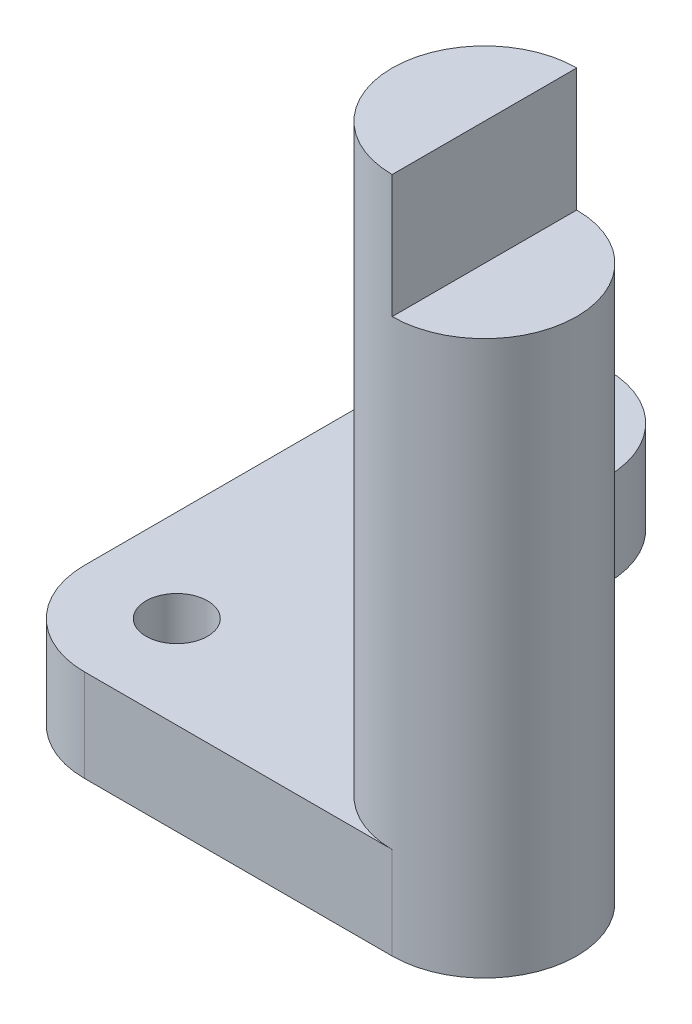
from build123d import *

# Parameters (mm, degrees)
SKETCH1_R           = 0.5
BOSS_EXTRUDE1_DEPTH = 1.5
SKETCH2_R           = 1.5
BOSS_EXTRUDE2_DEPTH = 12
SKETCH3_R           = 0.5
BOSS_EXTRUDE3_DEPTH = 1.5
SKETCH6_W           = 11.188914533
SKETCH6_H           = 9.773285444
CUT_EXTRUDE4_DEPTH  = 6
BOSS_EXTRUDE4_DEPTH = 2


with BuildPart() as part:
    # Sketch1 → Boss-Extrude1 (new body)
    with BuildSketch(Plane(origin=(0, 0, 0), x_dir=(1, 0, 0), z_dir=(0, 1, 0))):
        with BuildLine():
            Line((5, -1), (1.5, -1))
            Line((1.5, -1), (1.5, 2.5))
            Line((1.5, 2.5), (1.5, 3))
            ThreePointArc((1.5, 3), (0, 4.5), (-1.5, 3))
            Line((-1.5, 3), (-1.5, 2.5))
            Line((-1.5, 2.5), (-1.5, -2.5))
            ThreePointArc((-1.5, -2.5), (-1.060660172, -3.560660172), (0, -4))
            Line((0, -4), (5, -4))
            ThreePointArc((5, -4), (6.5, -2.5), (5, -1))
        make_face()
        with Locations((0, -2.5)):
            Circle(SKETCH1_R, mode=Mode.SUBTRACT)
        with BuildLine():
            Line((-0.5, 3), (-0.5, 2))
            ThreePointArc((-0.5, 2), (0, 1.5), (0.5, 2))
            Line((0.5, 2), (0.5, 3))
            ThreePointArc((0.5, 3), (0, 3.5), (-0.5, 3))
        make_face(mode=Mode.SUBTRACT)
    extrude(amount=BOSS_EXTRUDE1_DEPTH)

    # Sketch2 → Boss-Extrude2 (add)
    with BuildSketch(Plane(origin=(0, 1.5, 0), x_dir=(1, 0, 0), z_dir=(0, 1, 0))):
        with Locations((5, -2.5)):
            Circle(SKETCH2_R)
    extrude(amount=BOSS_EXTRUDE2_DEPTH)

    # Sketch3 → Boss-Extrude3 (add)
    with BuildSketch(Plane(origin=(0, 13.5, 0), x_dir=(1, 0, 0), z_dir=(0, 1, 0))):
        with BuildLine():
            Line((1.5, -1), (5, -1))
            ThreePointArc((5, -1), (6.5, -2.5), (5, -4))
            Line((5, -4), (0, -4))
            ThreePointArc((0, -4), (-1.060660172, -3.560660172), (-1.5, -2.5))
            Line((-1.5, -2.5), (-1.5, 2.5))
            Line((-1.5, 2.5), (-1.5, 3))
            ThreePointArc((-1.5, 3), (0, 4.5), (1.5, 3))
            Line((1.5, 3), (1.5, 2.5))
            Line((1.5, 2.5), (1.5, -1))
        make_face()
        with Locations((0, -2.5)):
            Circle(SKETCH3_R, mode=Mode.SUBTRACT)
        with BuildLine():
            Line((-0.5, 3), (-0.5, 2))
            ThreePointArc((-0.5, 2), (0, 1.5), (0.5, 2))
            Line((0.5, 2), (0.5, 3))
            ThreePointArc((0.5, 3), (0, 3.5), (-0.5, 3))
        make_face(mode=Mode.SUBTRACT)
    extrude(amount=BOSS_EXTRUDE3_DEPTH)

    # Sketch6 → Cut-Extrude4 (cut)
    with BuildSketch(Plane(origin=(0, 15, 0), x_dir=(1, 0, 0), z_dir=(0, 1, 0))):
        with Locations((1.642455456, 0.222776364)):
            Rectangle(SKETCH6_W, SKETCH6_H)
    extrude(amount=-CUT_EXTRUDE4_DEPTH, mode=Mode.SUBTRACT)

    # Sketch7 → Boss-Extrude4 (add)
    with BuildSketch(Plane(origin=(0, 9, 0), x_dir=(1, 0, 0), z_dir=(0, 1, 0))):
        with BuildLine():
            Line((5, -1), (5, -4))
            ThreePointArc((5, -4), (3.5, -2.5), (5, -1))
        make_face()
    extrude(amount=BOSS_EXTRUDE4_DEPTH)


solid = part.part
